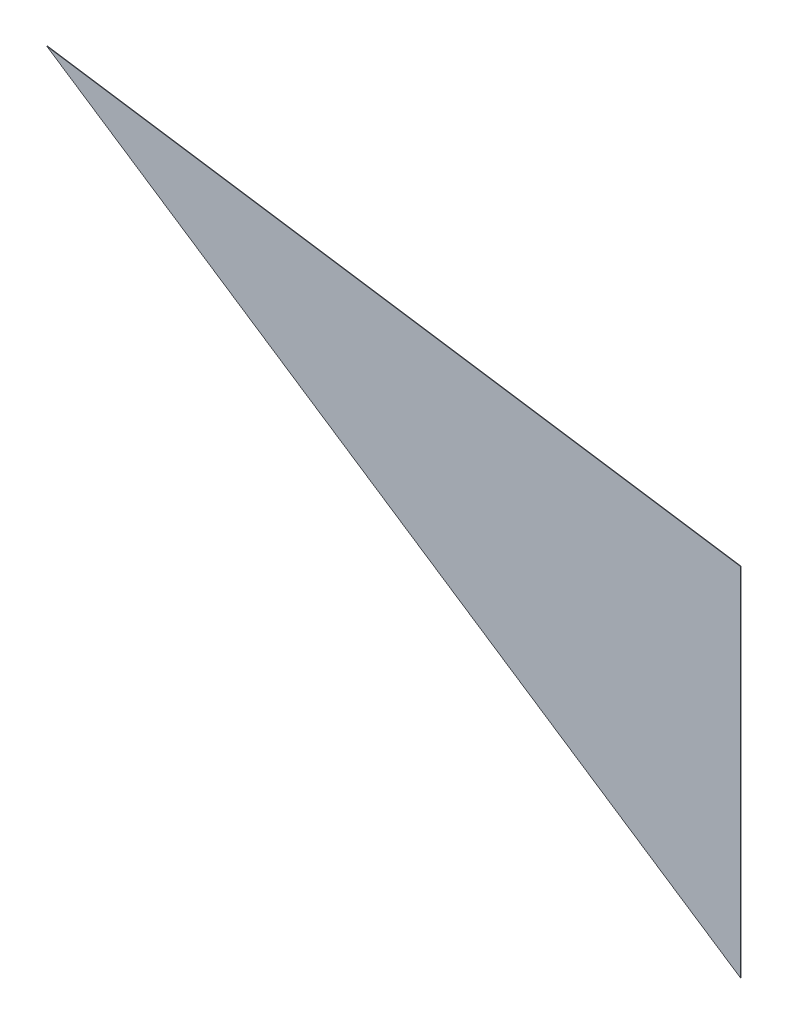
from build123d import *

# Parameters (mm, degrees)
DODANIE_WYCI_GNI_CIE1_DEPTH = 0.5


with BuildPart() as part:
    # Szkic1 → Dodanie-wyciągnięcie1 (new body)
    with BuildSketch(Plane.XY):
        Polygon((-210.680056235, 173.373216466), (-210.680056235, -159.825581885), (-859.317008092, 270.340623328), align=None)
    extrude(amount=DODANIE_WYCI_GNI_CIE1_DEPTH)


solid = part.part
